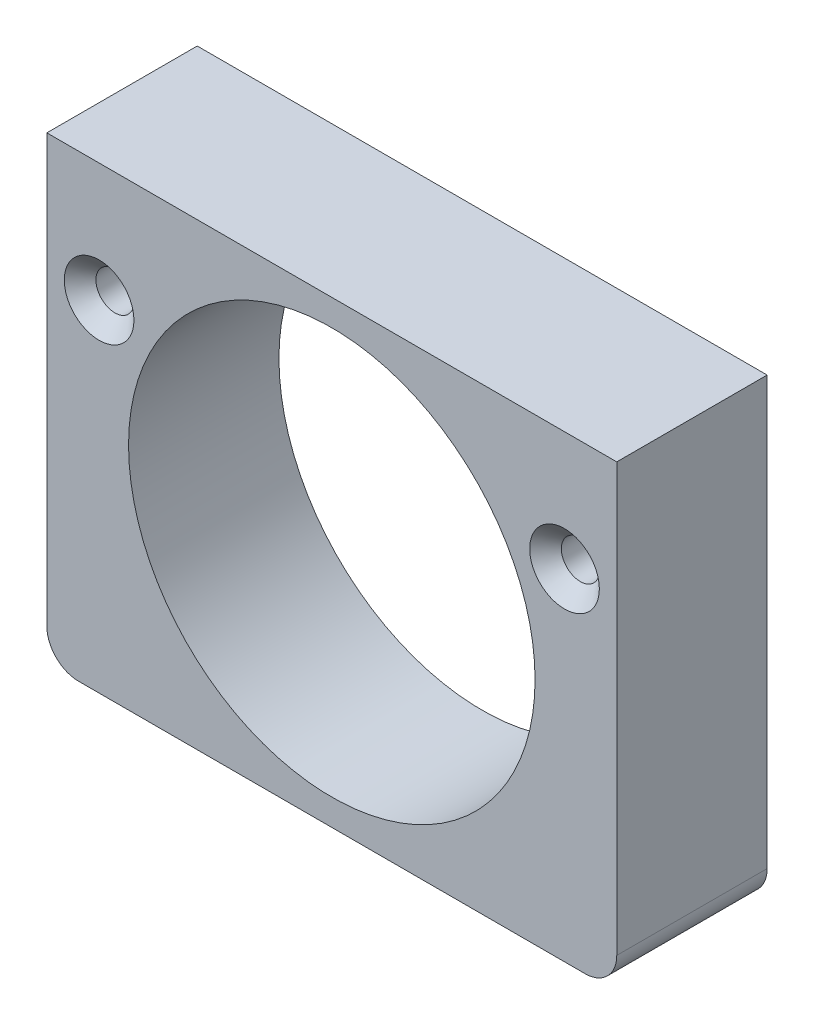
from build123d import *

# Parameters (mm, degrees)
BOSS_EXTRUDE1_DEPTH                                 = 9.5
CUT_EXTRUDE1_REACH                                  = 11.5
SKETCH2_R                                           = 12.8397
CSK_FOR_M2_COUNTERSUNK_FLAT_HEAD_SCREW1_D           = 2.4
CSK_FOR_M2_COUNTERSUNK_FLAT_HEAD_SCREW1_DEPTH       = 9.5
CSK_FOR_M2_COUNTERSUNK_FLAT_HEAD_SCREW1_CSINK_D     = 4.4
CSK_FOR_M2_COUNTERSUNK_FLAT_HEAD_SCREW1_CSINK_ANGLE = 90


with BuildPart() as part:
    # Sketch1 → Boss-Extrude1 (new body)
    with BuildSketch(Plane.XY):
        with BuildLine():
            Line((-16, -14.5), (16, -14.5))
            ThreePointArc((16, -14.5), (17.414213562, -13.914213562), (18, -12.5))
            Line((18, -12.5), (18, 14.5))
            Line((18, 14.5), (-18, 14.5))
            Line((-18, 14.5), (-18, -12.5))
            ThreePointArc((-18, -12.5), (-17.414213562, -13.914213562), (-16, -14.5))
        make_face()
    extrude(amount=BOSS_EXTRUDE1_DEPTH)

    # Sketch2 → Cut-Extrude1 (cut, up to next)
    with BuildSketch(Plane(origin=(0, 0, 9.5), x_dir=(0, 1, 0), z_dir=(0, 0, 1)), mode=Mode.PRIVATE) as cut_extrude1_sk1:
        Circle(SKETCH2_R)
    cut_extrude1_tool1 = extrude(cut_extrude1_sk1.sketch, amount=-CUT_EXTRUDE1_REACH, mode=Mode.PRIVATE) & part.part
    add(cut_extrude1_tool1.solids().sort_by_distance((0, 0, 9.5))[0], mode=Mode.SUBTRACT)

    # CSK for M2 Countersunk Flat Head Screw1
    with Locations(Plane.XY.offset(9.5)):
        with Locations((-14.7, 7), (14.7, 7)):
            CounterSinkHole(CSK_FOR_M2_COUNTERSUNK_FLAT_HEAD_SCREW1_D / 2, CSK_FOR_M2_COUNTERSUNK_FLAT_HEAD_SCREW1_CSINK_D / 2, depth=CSK_FOR_M2_COUNTERSUNK_FLAT_HEAD_SCREW1_DEPTH, counter_sink_angle=CSK_FOR_M2_COUNTERSUNK_FLAT_HEAD_SCREW1_CSINK_ANGLE)


solid = part.part
